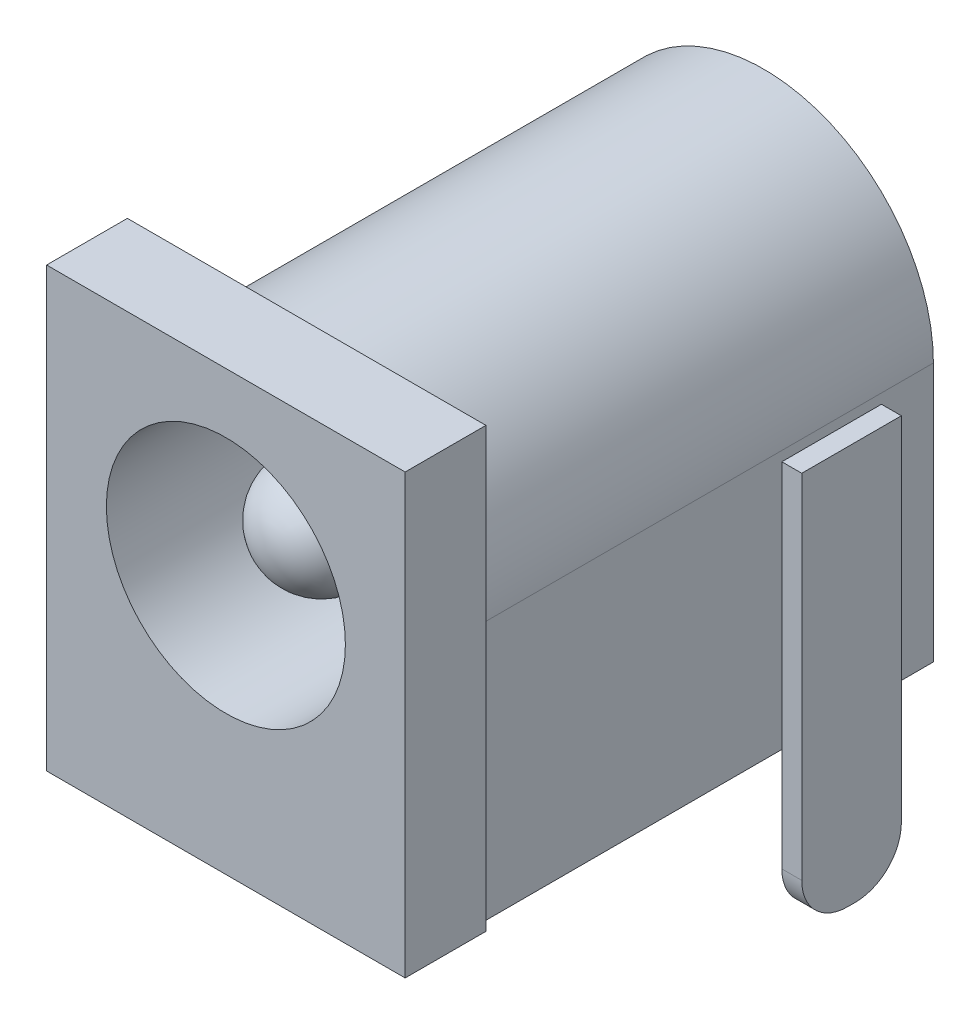
from build123d import *

# Parameters (mm, degrees)
SKETCH1_W           = 9
SKETCH1_H           = 11
EXTRUDE1_DEPTH      = 13.5
CUT_EXTRUDE1_DEPTH  = 11.472184734
SKETCH3_W           = 2.5
SKETCH3_H           = 0.5
SKETCH3_W_2         = 0.5
SKETCH3_H_2         = 2.5
EXTRUDE2_DEPTH      = 3.5
EXTRUDE2_DEPTH_BACK = 6.5
CUT_EXTRUDE2_START  = -0.5
CUT_EXTRUDE2_DEPTH  = 0.5
CUT_EXTRUDE3_DEPTH  = 6.37645
SKETCH6_R           = 3
CUT_EXTRUDE4_DEPTH  = 10.5
SKETCH7_R           = 1.341174798
EXTRUDE3_DEPTH      = 8.5
DOME1_FACE_RADIUS   = 1.341174798
DOME1_HEIGHT        = 1


with BuildPart() as part:
    # Sketch1 → Extrude1 (new body)
    with BuildSketch(Plane.XY):
        with Locations((4.5, 5.5)):
            Rectangle(SKETCH1_W, SKETCH1_H)
    extrude(amount=EXTRUDE1_DEPTH)

    # Sketch2 → Cut-Extrude1 (cut)
    with BuildSketch(Plane(origin=(0, 0, 0), x_dir=(-1, 0, 0), z_dir=(0, 0, -1))):
        with BuildLine():
            Line((-8.759861733, 6.5), (-8.759861733, 0))
            Line((-8.759861733, 0), (-10.235511259, 0))
            Line((-10.235511259, 0), (-10.235511259, 11.286267996))
            Line((-10.235511259, 11.286267996), (1.276116648, 11.286267996))
            Line((1.276116648, 11.286267996), (1.276116648, 0))
            Line((1.276116648, 0), (-0.240138267, 0))
            Line((-0.240138267, 0), (-0.240138267, 6.5))
            ThreePointArc((-0.240138267, 6.5), (-4.5, 10.759861733), (-8.759861733, 6.5))
        make_face()
    extrude(amount=-CUT_EXTRUDE1_DEPTH, mode=Mode.SUBTRACT)

    # Sketch3 → Extrude2 (add, two sides)
    with BuildSketch(Plane.XZ) as extrude2_sk:
        with Locations((4.5, 5.8)):
            Rectangle(SKETCH3_W, SKETCH3_H)
        with Locations((9.255436424, 2.8)):
            Rectangle(SKETCH3_W_2, SKETCH3_H_2)
        with Locations((4.5, -0.076449713)):
            Rectangle(SKETCH3_W, SKETCH3_H)
    extrude(amount=EXTRUDE2_DEPTH)
    extrude(extrude2_sk.sketch, amount=-EXTRUDE2_DEPTH_BACK)

    # Sketch4 → Cut-Extrude2 (cut)
    with BuildSketch(Plane(origin=(9.505436424, 0, 0), x_dir=(0, 0, -1), z_dir=(1, 0, 0)).offset(CUT_EXTRUDE2_START)):
        with BuildLine():
            Line((-1.55, 0.401221022), (-0.317888933, 0.401221022))
            Line((-0.317888933, 0.401221022), (-0.317888933, -4.045287891))
            Line((-0.317888933, -4.045287891), (-5.095635432, -4.045287891))
            Line((-5.095635432, -4.045287891), (-5.095635432, 0.401221022))
            Line((-5.095635432, 0.401221022), (-4.05, 0.401221022))
            Line((-4.05, 0.401221022), (-4.05, -2.35))
            ThreePointArc((-4.05, -2.35), (-3.713172798, -3.163172798), (-2.9, -3.5))
            Line((-2.9, -3.5), (-2.7, -3.5))
            ThreePointArc((-2.7, -3.5), (-1.886827202, -3.163172798), (-1.55, -2.35))
            Line((-1.55, -2.35), (-1.55, 0.401221022))
        make_face()
    extrude(amount=CUT_EXTRUDE2_DEPTH, mode=Mode.SUBTRACT)

    # Sketch5 → Cut-Extrude3 (cut)
    with BuildSketch(Plane(origin=(0, 0, -0.326449713), x_dir=(-1, 0, 0), z_dir=(0, 0, -1))):
        with BuildLine():
            Line((-3.25, -0.558332619), (-2.247520265, -0.558332619))
            Line((-2.247520265, -0.558332619), (-2.247520265, -4.051690435))
            Line((-2.247520265, -4.051690435), (-6.966055813, -4.051690435))
            Line((-6.966055813, -4.051690435), (-6.966055813, -0.558332619))
            Line((-6.966055813, -0.558332619), (-5.75, -0.558332619))
            Line((-5.75, -0.558332619), (-5.75, -2.35))
            ThreePointArc((-5.75, -2.35), (-5.413172798, -3.163172798), (-4.6, -3.5))
            Line((-4.6, -3.5), (-4.4, -3.5))
            ThreePointArc((-4.4, -3.5), (-3.586827202, -3.163172798), (-3.25, -2.35))
            Line((-3.25, -2.35), (-3.25, -0.558332619))
        make_face()
    extrude(amount=-CUT_EXTRUDE3_DEPTH, mode=Mode.SUBTRACT)

    # Sketch6 → Cut-Extrude4 (cut)
    with BuildSketch(Plane.XY.offset(13.5)):
        with Locations((4.5, 6.5)):
            Circle(SKETCH6_R)
    extrude(amount=-CUT_EXTRUDE4_DEPTH, mode=Mode.SUBTRACT)

    # Sketch7 → Extrude3 (add)
    with BuildSketch(Plane.XY.offset(3)):
        with Locations((4.5, 6.5)):
            Circle(SKETCH7_R)
    extrude(amount=EXTRUDE3_DEPTH)

    # Dome1: a dome of height H over a round flat face of radius A is a cap of a sphere of radius (A * A + H * H) / (2 * H)
    dome1_r = (DOME1_FACE_RADIUS * DOME1_FACE_RADIUS + DOME1_HEIGHT * DOME1_HEIGHT) / (2 * DOME1_HEIGHT)
    dome1_base = Plane((4.5, 6.5, 11.5), z_dir=(0, 0, 1))
    with Locations(dome1_base.offset(DOME1_HEIGHT - dome1_r)):
        dome1_ball = Sphere(dome1_r, mode=Mode.PRIVATE)
    add(split(dome1_ball, bisect_by=dome1_base, keep=Keep.TOP, mode=Mode.PRIVATE))


solid = part.part
